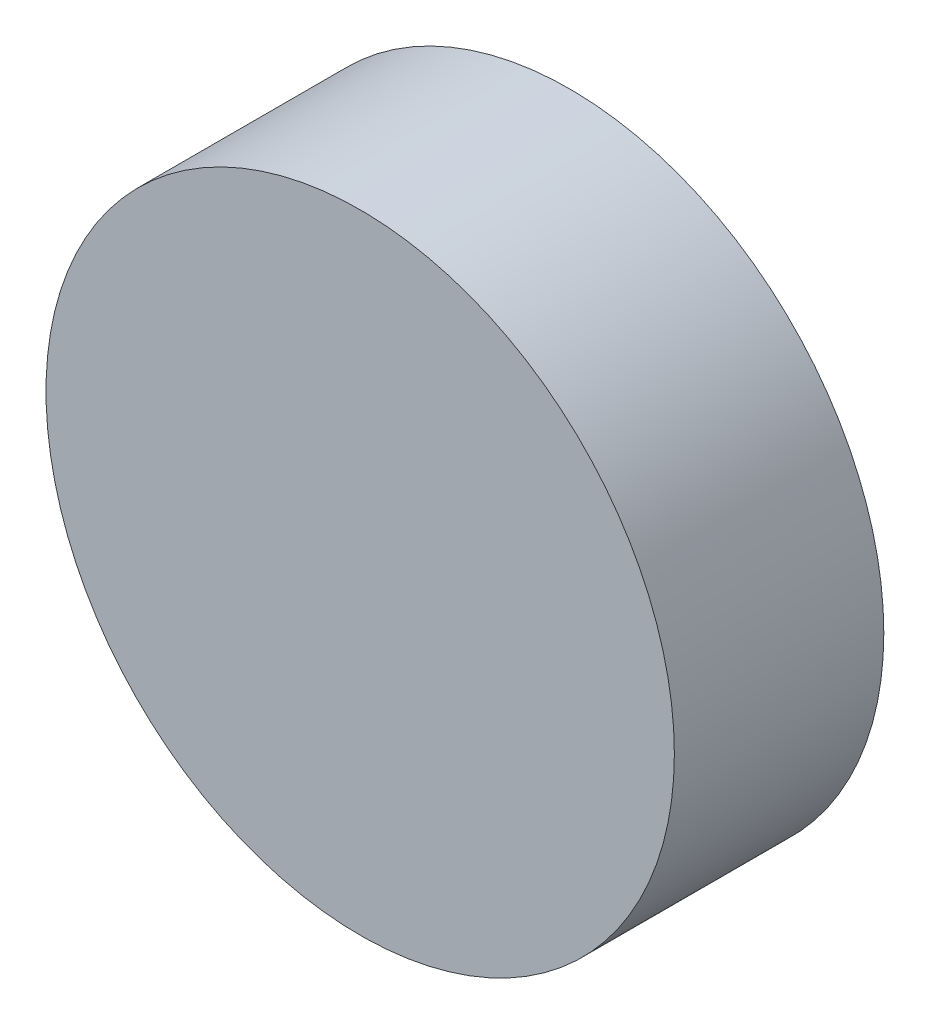
from build123d import *

# Parameters (mm, degrees)
WHEEL_CROSS_SECTION_R = 152.4
DRIVE_WHEEL_DEPTH     = 50.8


with BuildPart() as part:
    # Wheel Cross Section → Drive Wheel (new body, symmetric)
    with BuildSketch(Plane.XY):
        Circle(WHEEL_CROSS_SECTION_R)
    extrude(amount=DRIVE_WHEEL_DEPTH, both=True)


solid = part.part
